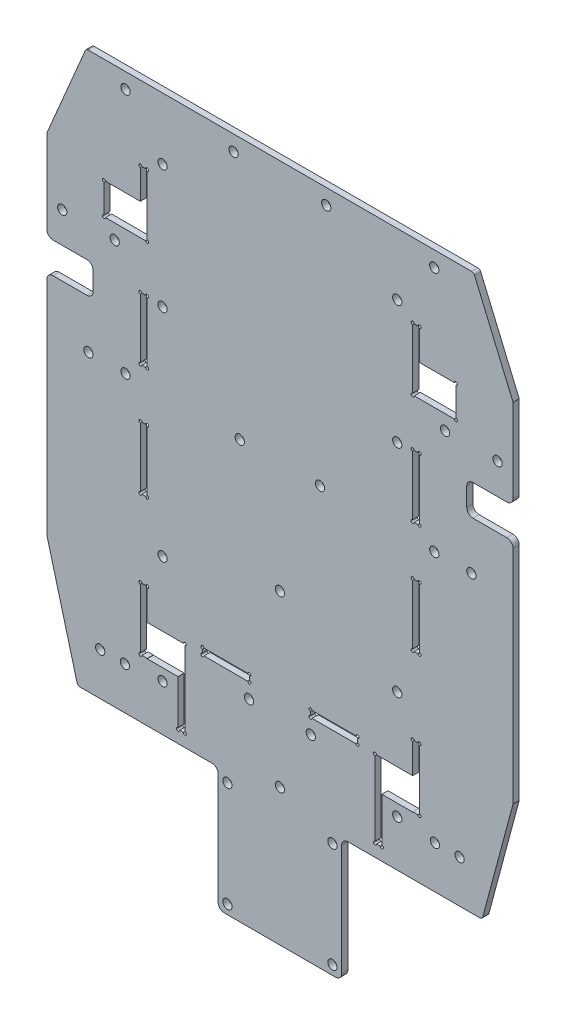
from build123d import *

# Parameters (mm, degrees)
SKETCH_1_R          = 1.5
SKETCH_1_W          = 2.2
SKETCH_1_H          = 20.2
SKETCH_1_W_2        = 15.2
SKETCH_1_H_2        = 2.2
EXTRUDE_1_DEPTH     = 2
SKETCH_2_W          = 14
SKETCH_2_H          = 10.2
SKETCH_2_R          = 1.5
CUT_EXTRUDE_1_DEPTH = 3
SKETCH_3_R          = 0.5
CUT_EXTRUDE_2_DEPTH = 3
SKETCH_4_R          = 1.5
CUT_EXTRUDE_3_DEPTH = 5
SKETCH_5_R          = 1.5
CUT_EXTRUDE_4_DEPTH = 2
FILLET_1_R          = 1
SKETCH_6_W          = 15
SKETCH_6_H          = 10
CUT_EXTRUDE_5_DEPTH = 10
FILLET_2_R          = 2
SKETCH_7_W          = 40
SKETCH_7_H          = 40
SKETCH_7_R          = 1.5
EXTRUDE_2_DEPTH     = 2
FILLET_3_R          = 2


with BuildPart() as part:
    # 草图1 → 凸台-拉伸1 (new body)
    with BuildSketch(Plane.XY):
        Polygon((62.765755514, 90), (-62.765755514, 90), (-75.5, 60), (-75.5, -52.679491924), (-65.5, -90), (65.5, -90), (75.5, -52.679491924), (75.5, 60), align=None)
        with Locations((50, 85)):
            Circle(SKETCH_1_R, mode=Mode.SUBTRACT)
        with Locations((15, 85)):
            Circle(SKETCH_1_R, mode=Mode.SUBTRACT)
        with Locations((-15, 85)):
            Circle(SKETCH_1_R, mode=Mode.SUBTRACT)
        with Locations((-50, 85)):
            Circle(SKETCH_1_R, mode=Mode.SUBTRACT)
        with Locations((-44.1, 55.9)):
            Rectangle(SKETCH_1_W, SKETCH_1_H, mode=Mode.SUBTRACT)
        with Locations((-44.1, 20.4)):
            Rectangle(SKETCH_1_W, SKETCH_1_H, mode=Mode.SUBTRACT)
        with Locations((-44.1, -15.8)):
            Rectangle(SKETCH_1_W, SKETCH_1_H, mode=Mode.SUBTRACT)
        with Locations((44.1, -15.8)):
            Rectangle(SKETCH_1_W, SKETCH_1_H, mode=Mode.SUBTRACT)
        with Locations((44.1, 20.4)):
            Rectangle(SKETCH_1_W, SKETCH_1_H, mode=Mode.SUBTRACT)
        with Locations((44.1, 55.9)):
            Rectangle(SKETCH_1_W, SKETCH_1_H, mode=Mode.SUBTRACT)
        with Locations((44.1, -61)):
            Rectangle(SKETCH_1_W, SKETCH_1_H, mode=Mode.SUBTRACT)
        with Locations((-44.1, -61)):
            Rectangle(SKETCH_1_W, SKETCH_1_H, mode=Mode.SUBTRACT)
        with Locations((17.5, -60.1)):
            Rectangle(SKETCH_1_W_2, SKETCH_1_H_2, mode=Mode.SUBTRACT)
        with Locations((-17.5, -60.1)):
            Rectangle(SKETCH_1_W_2, SKETCH_1_H_2, mode=Mode.SUBTRACT)
    extrude(amount=EXTRUDE_1_DEPTH)

    # 草图2 → 切除-拉伸1 (cut, through all)
    with BuildSketch(Plane(origin=(0, 0, 0), x_dir=(-1, 0, 0), z_dir=(0, 0, -1))):
        with Locations((-50, 50.9)):
            Rectangle(SKETCH_2_W, SKETCH_2_H)
        Polygon((43, -61), (30.8, -61), (30.8, -86), (33, -86), (33, -71.2), (43, -71.2), align=None)
        with Locations((50, 50.9)):
            Rectangle(SKETCH_2_W, SKETCH_2_H)
        Polygon((-43, -71.2), (-33, -71.2), (-33, -86), (-30.8, -86), (-30.8, -61), (-43, -61), align=None)
        with Locations((-38, 30)):
            Circle(SKETCH_2_R)
        with Locations((-38, -40)):
            Circle(SKETCH_2_R)
        with Locations((38, 30)):
            Circle(SKETCH_2_R)
        with Locations((38, -40)):
            Circle(SKETCH_2_R)
        with Locations((38, -75)):
            Circle(SKETCH_2_R)
        with Locations((-38, -75)):
            Circle(SKETCH_2_R)
        with Locations((38, 70)):
            Circle(SKETCH_2_R)
        with Locations((-38, 70)):
            Circle(SKETCH_2_R)
        with Locations((-50, 5.3)):
            Circle(SKETCH_2_R)
        with Locations((13, 5.3)):
            Circle(SKETCH_2_R)
        with Locations((-13, 5.3)):
            Circle(SKETCH_2_R)
        with Locations((50, 5.3)):
            Circle(SKETCH_2_R)
        with Locations((62, 5.3)):
            Circle(SKETCH_2_R)
        with Locations((-62, 5.3)):
            Circle(SKETCH_2_R)
        with Locations((0, -30.7)):
            Circle(SKETCH_2_R)
        with Locations((0, -85.7)):
            Circle(SKETCH_2_R)
        with Locations((10, -66)):
            Circle(SKETCH_2_R)
        with Locations((-10, -66)):
            Circle(SKETCH_2_R)
    extrude(amount=-CUT_EXTRUDE_1_DEPTH, mode=Mode.SUBTRACT)

    # 草图3 → 切除-拉伸2 (cut, through all)
    with BuildSketch(Plane(origin=(0, 0, 0), x_dir=(-1, 0, 0), z_dir=(0, 0, -1))):
        with Locations((-57, 56)):
            Circle(SKETCH_3_R)
        with Locations((-57, 45.8)):
            Circle(SKETCH_3_R)
        with Locations((-45.2, 66)):
            Circle(SKETCH_3_R)
        with Locations((-43, 45.8)):
            Circle(SKETCH_3_R)
        with Locations((-45.2, 30.5)):
            Circle(SKETCH_3_R)
        with Locations((-45.2, 10.3)):
            Circle(SKETCH_3_R)
        with Locations((-45.2, -5.7)):
            Circle(SKETCH_3_R)
        with Locations((-45.2, -25.9)):
            Circle(SKETCH_3_R)
        with Locations((-45.2, -50.9)):
            Circle(SKETCH_3_R)
        with Locations((-45.2, -71.1)):
            Circle(SKETCH_3_R)
        with Locations((-30.8, -61)):
            Circle(SKETCH_3_R)
        with Locations((-33, -86)):
            Circle(SKETCH_3_R)
        with Locations((-43, -50.9)):
            Circle(SKETCH_3_R)
        with Locations((-43, -25.9)):
            Circle(SKETCH_3_R)
        with Locations((-43, -5.7)):
            Circle(SKETCH_3_R)
        with Locations((-43, 10.3)):
            Circle(SKETCH_3_R)
        with Locations((-43, 30.5)):
            Circle(SKETCH_3_R)
        with Locations((-43, 66)):
            Circle(SKETCH_3_R)
        with Locations((-30.8, -86)):
            Circle(SKETCH_3_R)
        with Locations((-25.1, -59)):
            Circle(SKETCH_3_R)
        with Locations((-25.1, -61.2)):
            Circle(SKETCH_3_R)
        with Locations((-9.9, -61.2)):
            Circle(SKETCH_3_R)
        with Locations((-9.9, -59)):
            Circle(SKETCH_3_R)
        with Locations((9.9, -59)):
            Circle(SKETCH_3_R)
        with Locations((9.9, -61.2)):
            Circle(SKETCH_3_R)
        with Locations((25.1, -61.2)):
            Circle(SKETCH_3_R)
        with Locations((25.1, -59)):
            Circle(SKETCH_3_R)
        with Locations((30.8, -86)):
            Circle(SKETCH_3_R)
        with Locations((43, 66)):
            Circle(SKETCH_3_R)
        with Locations((43, 30.5)):
            Circle(SKETCH_3_R)
        with Locations((43, 10.3)):
            Circle(SKETCH_3_R)
        with Locations((43, -5.7)):
            Circle(SKETCH_3_R)
        with Locations((43, -25.9)):
            Circle(SKETCH_3_R)
        with Locations((43, -50.9)):
            Circle(SKETCH_3_R)
        with Locations((33, -86)):
            Circle(SKETCH_3_R)
        with Locations((30.8, -61)):
            Circle(SKETCH_3_R)
        with Locations((45.2, -71.1)):
            Circle(SKETCH_3_R)
        with Locations((45.2, -50.9)):
            Circle(SKETCH_3_R)
        with Locations((45.2, -25.9)):
            Circle(SKETCH_3_R)
        with Locations((45.2, -5.7)):
            Circle(SKETCH_3_R)
        with Locations((45.2, 10.3)):
            Circle(SKETCH_3_R)
        with Locations((45.2, 30.5)):
            Circle(SKETCH_3_R)
        with Locations((43, 45.8)):
            Circle(SKETCH_3_R)
        with Locations((45.2, 66)):
            Circle(SKETCH_3_R)
        with Locations((57, 45.8)):
            Circle(SKETCH_3_R)
        with Locations((57, 56)):
            Circle(SKETCH_3_R)
    extrude(amount=-CUT_EXTRUDE_2_DEPTH, mode=Mode.SUBTRACT)

    # 草图4 → 切除-拉伸3 (cut)
    with BuildSketch(Plane(origin=(0, 0, 0), x_dir=(-1, 0, 0), z_dir=(0, 0, -1))):
        with Locations((-58.2, -76.2)):
            Circle(SKETCH_4_R)
        with Locations((-50.2, -76.2)):
            Circle(SKETCH_4_R)
        with Locations((58.2, -76.2)):
            Circle(SKETCH_4_R)
        with Locations((50.2, -76.2)):
            Circle(SKETCH_4_R)
    extrude(amount=-CUT_EXTRUDE_3_DEPTH, mode=Mode.SUBTRACT)

    # 草图5 → 切除-拉伸4 (cut)
    with BuildSketch(Plane(origin=(0, 0, 0), x_dir=(-1, 0, 0), z_dir=(0, 0, -1))):
        with Locations((-53.5, 41)):
            Circle(SKETCH_5_R)
        with Locations((-70.5, 41)):
            Circle(SKETCH_5_R)
        with Locations((53.5, 41)):
            Circle(SKETCH_5_R)
        with Locations((70.5, 41)):
            Circle(SKETCH_5_R)
    extrude(amount=-CUT_EXTRUDE_4_DEPTH, mode=Mode.SUBTRACT)

    # 圆角1
    fillet_1_edges = [part.edges().sort_by_distance(p)[0] for p in [
        (-62.765755514, 90, 1),
        (62.765755514, 90, 1),
        (65.5, -90, 1),
        (-65.5, -90, 1),
    ]]
    fillet(fillet_1_edges, radius=FILLET_1_R)

    # 草图6 → 切除-拉伸5 (cut)
    with BuildSketch(Plane.XY.offset(2)):
        with Locations((-68, 26)):
            Rectangle(SKETCH_6_W, SKETCH_6_H)
        with Locations((68, 26)):
            Rectangle(SKETCH_6_W, SKETCH_6_H)
    extrude(amount=-CUT_EXTRUDE_5_DEPTH, mode=Mode.SUBTRACT)

    # 圆角2
    fillet_2_edges = [part.edges().sort_by_distance(p)[0] for p in [
        (75.5, 31, 1),
        (75.5, 21, 1),
        (-75.5, 21, 1),
        (-75.5, 31, 1),
        (-60.5, 31, 1),
        (-60.5, 21, 1),
        (60.5, 21, 1),
        (60.5, 31, 1),
    ]]
    fillet(fillet_2_edges, radius=FILLET_2_R)

    # 草图7 → 凸台-拉伸2 (add)
    with BuildSketch(Plane.XY.offset(2)):
        with Locations((0, -110)):
            Rectangle(SKETCH_7_W, SKETCH_7_H)
        with Locations((-17, -93)):
            Circle(SKETCH_7_R, mode=Mode.SUBTRACT)
        with Locations((17, -93)):
            Circle(SKETCH_7_R, mode=Mode.SUBTRACT)
        with Locations((-17, -127)):
            Circle(SKETCH_7_R, mode=Mode.SUBTRACT)
        with Locations((17, -127)):
            Circle(SKETCH_7_R, mode=Mode.SUBTRACT)
    extrude(amount=-EXTRUDE_2_DEPTH)

    # 圆角3
    fillet_3_edges = [part.edges().sort_by_distance(p)[0] for p in [
        (-20, -130, 1),
        (-20, -90, 1),
        (20, -90, 1),
        (20, -130, 1),
    ]]
    fillet(fillet_3_edges, radius=FILLET_3_R)


solid = part.part
